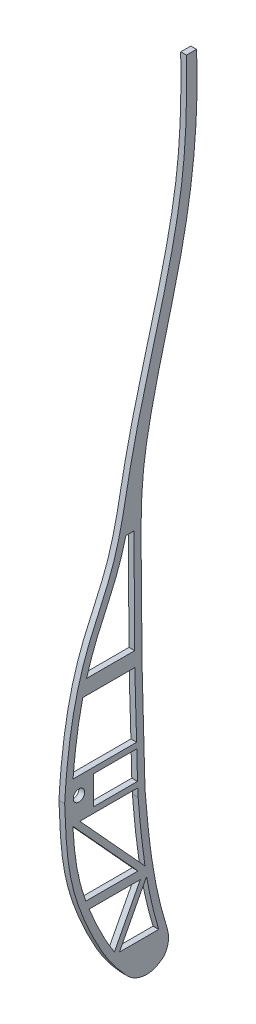
from build123d import *

# Parameters (mm, degrees)
SKETCH5_R           = 2
BOSS_EXTRUDE4_DEPTH = 2


with BuildPart() as part:
    # Sketch5 → Boss-Extrude4 (new body)
    with BuildSketch(Plane(origin=(0, 0, 0), x_dir=(0, 0, -1), z_dir=(1, 0, 0))):
        with BuildLine():
            Line((702.204816823, 368.641580619), (702.335041252, 365.911608116))
            add(Edge.make_bspline(
                [(708.665069398, 312.915202561), (709.059599228, 313.283182522), (711.326824284, 316.980719887), (705.479336728, 334.207550543), (703.629367545, 350.093853303), (702.335041252, 365.911608116)],
                knots=[0.204758752, 0.204758752, 0.204758752, 0.204758752, 0.20789537, 0.236848005, 0.393768065, 0.393768065, 0.393768065, 0.393768065], degree=3))
            Line((708.665069398, 312.915202561), (708.4849665, 312.753960248))
            add(Edge.make_bspline(
                [(674.154545228, 376.641580619), (674.620856382, 363.904715947), (675.424379165, 348.971791483), (687.000536051, 324.673360926), (691.715046417, 318.305462816), (697.505420821, 311.905575317), (699.991161169, 310.504584491), (704.896179602, 310.578107779), (707.173869325, 311.62539673), (708.4849665, 312.753960248)],
                knots=[0, 0, 0, 0, 0.082296827, 0.137776908, 0.177734591, 0.177734591, 0.194632136, 0.194632136, 0.204299624, 0.204299624, 0.204299624, 0.204299624], degree=3))
            add(Edge.make_bspline(
                [(716.738350356, 582.041790112), (716.949059787, 569.658613326), (716.383977532, 531.252800378), (699.20164784, 484.745643735), (692.816603357, 441.17567074), (677.838033392, 413.403031345), (675.017147904, 391.169841826), (674.154545228, 376.641580619)],
                knots=[0, 0, 0, 0, 0.169561978, 0.555938321, 0.689282964, 0.79105623, 1, 1, 1, 1], degree=3))
            Line((716.738350356, 582.041790112), (720.275191601, 582.041790112))
            add(Edge.make_bspline(
                [(702.204816823, 368.641580619), (701.866880483, 376.59261731), (701.855512377, 384.742525801), (701.126563426, 402.784012347), (701.139569257, 431.740463498), (700.554364903, 456.925362173), (705.113280793, 487.005006805), (717.55757455, 525.169688046), (721.077969059, 562.139389647), (720.275191601, 582.041790112)],
                knots=[0.402967304, 0.402967304, 0.402967304, 0.402967304, 0.483086215, 0.483086215, 0.591391283, 0.687653006, 0.687653006, 0.844632598, 1, 1, 1, 1], degree=3))
        make_face()
        with Locations((679.154545228, 376.641580619)):
            Circle(SKETCH5_R, mode=Mode.SUBTRACT)
        with BuildLine():
            Line((693.31700457, 322.101474261), (707.046446766, 322.101474261))
            add(Edge.make_bspline(
                [(707.046446766, 322.101474261), (707.005220945, 322.237117772), (706.922732707, 322.509383939), (706.534234053, 323.800299861), (705.907689381, 326.016954973), (705.086335684, 329.174913084), (704.081146672, 333.458245954), (703.342146452, 337.155046299), (702.879683114, 339.794769321), (702.796205667, 340.283443291)],
                knots=[0.237992564, 0.237992564, 0.237992564, 0.237992564, 0.239469199, 0.240945834, 0.25201108, 0.263824162, 0.275637244, 0.299263408, 0.304623067, 0.304623067, 0.304623067, 0.304623067], degree=3))
            Line((702.796205667, 340.283443291), (693.31700457, 322.101474261))
        make_face(mode=Mode.SUBTRACT)
        with BuildLine():
            Line((695.569646388, 447.110102342), (698.373565229, 447.110102342))
            add(Edge.make_bspline(
                [(698.664232879, 410.731591223), (698.643793767, 412.705167832), (698.583200964, 419.576888227), (698.503020609, 431.741041677), (698.342615508, 441.708845907), (698.371128999, 446.773860567), (698.373565229, 447.110102342)],
                knots=[0.536768619, 0.536768619, 0.536768619, 0.536768619, 0.552225478, 0.589540022, 0.626854565, 0.629511103, 0.629511103, 0.629511103, 0.629511103], degree=3))
            Line((698.664232879, 410.731591223), (681.819733297, 410.731591223))
            add(Edge.make_bspline(
                [(695.569646388, 447.110102342), (695.445071663, 446.615479316), (694.75574098, 443.952002178), (693.309217828, 439.14083074), (690.757463872, 432.870717043), (687.981879888, 426.835905874), (685.294048363, 420.88837637), (683.281845592, 415.556583016), (682.219049797, 412.125988091), (681.819733297, 410.731591223)],
                knots=[0.649129365, 0.649129365, 0.649129365, 0.649129365, 0.65625, 0.6875, 0.71875, 0.75, 0.78125, 0.8125, 0.833614827, 0.833614827, 0.833614827, 0.833614827], degree=3))
        make_face(mode=Mode.SUBTRACT)
        with BuildLine():
            Line((698.726070785, 405.587845941), (680.484664022, 405.587845941))
            add(Edge.make_bspline(
                [(680.484664022, 405.587845941), (680.238750128, 404.537768108), (679.082225719, 399.268568047), (677.912154024, 391.590456054), (677.269554608, 384.953250969), (677.080076983, 382.641580619)],
                knots=[0.85935712, 0.85935712, 0.85935712, 0.85935712, 0.875, 0.9375, 0.970920894, 0.970920894, 0.970920894, 0.970920894], degree=3))
            Line((677.080076983, 382.641580619), (699.321524117, 382.641580619))
            add(Edge.make_bspline(
                [(699.321524117, 382.641580619), (699.302429137, 383.533434317), (699.242491888, 386.264575946), (699.147553202, 389.867098627), (699.001388629, 393.402101288), (698.877999212, 397.273483995), (698.789925818, 401.362239475), (698.740065111, 404.5905262), (698.726070785, 405.587845941)],
                knots=[0.449941277, 0.449941277, 0.449941277, 0.449941277, 0.458939119, 0.477596391, 0.486925027, 0.496253663, 0.514910935, 0.523066849, 0.523066849, 0.523066849, 0.523066849], degree=3))
        make_face(mode=Mode.SUBTRACT)
        with BuildLine():
            Line((699.702579346, 368.641580618), (679.480276131, 368.641580618))
            Line((679.480276131, 368.641580618), (702.244491297, 343.710296775))
            add(Edge.make_bspline(
                [(702.244491297, 343.710296775), (702.164114891, 344.240659424), (701.765665969, 346.944766745), (701.138245114, 351.874517683), (700.558148125, 357.51933203), (700.140198351, 362.144721019), (699.940108697, 364.525481943), (699.84336911, 365.707720979)],
                knots=[0.317111807, 0.317111807, 0.317111807, 0.317111807, 0.322889573, 0.346515737, 0.370141901, 0.381954983, 0.393768065, 0.393768065, 0.393768065, 0.393768065], degree=3))
            Line((699.84336911, 365.707720979), (699.707071806, 368.535421028))
            add(Edge.make_bspline(
                [(699.707071806, 368.535421028), (699.705567812, 368.570807306), (699.704070344, 368.606193837), (699.702579346, 368.641580618)],
                knots=[0.402967304, 0.402967304, 0.402967304, 0.402967304, 0.40332009, 0.40332009, 0.40332009, 0.40332009], degree=3))
        make_face(mode=Mode.SUBTRACT)
        Polygon((684.218074476, 380.641580619), (684.218074476, 370.641580619), (699.624833146, 370.641580619), (699.363874416, 380.641580619), align=None, mode=Mode.SUBTRACT)
        with BuildLine():
            Line((682.1263391, 343.420706069), (681.559097296, 343.420706069))
            add(Edge.make_bspline(
                [(677.018744633, 368.371328907), (677.019235664, 368.362579282), (677.068066295, 367.493376401), (677.225723278, 364.955099862), (677.566914997, 360.96060035), (678.163690756, 356.403379957), (679.010318197, 351.953931669), (680.115843128, 347.680414445), (681.068328365, 344.787866734), (681.559097296, 343.420706069)],
                knots=[0.019088183, 0.019088183, 0.019088183, 0.019088183, 0.01915309, 0.025537453, 0.03830618, 0.051074906, 0.063843633, 0.076612359, 0.087746996, 0.087746996, 0.087746996, 0.087746996], degree=3))
            Line((677.018744633, 368.371328907), (699.800617822, 343.420706068))
            Line((699.800617822, 343.420706068), (682.1263391, 343.420706069))
        make_face(mode=Mode.SUBTRACT)
        with BuildLine():
            Line((700.610911268, 340.418082885), (682.698490087, 340.418082885))
            add(Edge.make_bspline(
                [(682.698490087, 340.418082885), (683.012088003, 339.63205833), (683.994851073, 337.255773782), (685.764831958, 333.363896697), (687.973478624, 329.010987916), (689.749302302, 325.86156191), (690.898907805, 324.009354103), (691.392671247, 323.260742331), (691.546588362, 323.031887901)],
                knots=[0.095831225, 0.095831225, 0.095831225, 0.095831225, 0.102149812, 0.114918539, 0.127687265, 0.140455992, 0.146840355, 0.149678179, 0.149678179, 0.149678179, 0.149678179], degree=3))
            Line((691.546588362, 323.031887901), (700.610911268, 340.418082885))
        make_face(mode=Mode.SUBTRACT)
    extrude(amount=BOSS_EXTRUDE4_DEPTH)


solid = part.part
